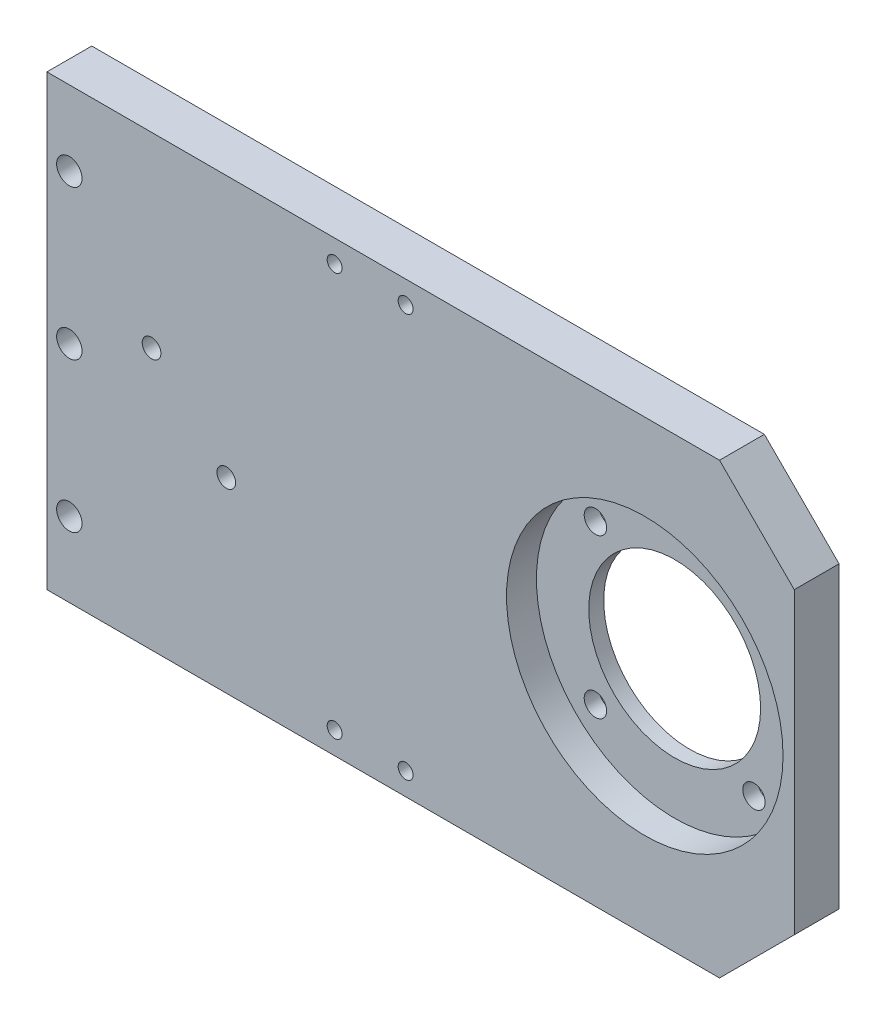
from build123d import *

# Parameters (mm, degrees)
SKETCH_1_W                = 100
SKETCH_1_H                = 60
EXTRUDE_1_DEPTH           = 6
SKETCH_2_R                = 11.5
SKETCH_2_R_2              = 1.5
CUT_EXTRUDE_1_DEPTH       = 10
SKETCH_3_R                = 18.5
CUT_EXTRUDE_2_DEPTH       = 4
HOLE_WIZARD_2_D           = 3.4
HOLE_WIZARD_2_CSINK_D     = 6.6
HOLE_WIZARD_2_CSINK_ANGLE = 90
CHAMFER_1_SIZE            = 10
HOLE_WIZARD_M3_1_D        = 2.5
HOLE_WIZARD_M3_1_DEPTH    = 7.5
HOLE_WIZARD_M3_1_TIP      = 0.751075774
SKETCH_16_R               = 1
CUT_EXTRUDE_3_DEPTH       = 6


with BuildPart() as part:
    # 草图1 → 凸台-拉伸1 (new body)
    with BuildSketch(Plane.XY):
        Rectangle(SKETCH_1_W, SKETCH_1_H)
    extrude(amount=EXTRUDE_1_DEPTH)

    # 草图2 → 切除-拉伸1 (cut)
    with BuildSketch(Plane.XY.offset(6)):
        with Locations((30, -8.8724e-05)):
            Circle(SKETCH_2_R)
        with Locations((40.606601718, 10.606512994)):
            Circle(SKETCH_2_R_2)
        with Locations((40.606601718, -10.606690441)):
            Circle(SKETCH_2_R_2)
        with Locations((19.393398282, 10.606512994)):
            Circle(SKETCH_2_R_2)
        with Locations((19.393398282, -10.606690441)):
            Circle(SKETCH_2_R_2)
    extrude(amount=-CUT_EXTRUDE_1_DEPTH, mode=Mode.SUBTRACT)

    # 草图3 → 切除-拉伸2 (cut)
    with BuildSketch(Plane.XY.offset(6)):
        with Locations((30, -8.8724e-05)):
            Circle(SKETCH_3_R)
    extrude(amount=-CUT_EXTRUDE_2_DEPTH, mode=Mode.SUBTRACT)

    # 打孔尺寸(%根据十字)槽半沉头木螺钉的类型2 (through all)
    with Locations(Plane(origin=(0, 0, 0), x_dir=(-1, 0, 0), z_dir=(0, 0, -1))):
        with Locations((47, -20), (47, 0), (47, 20)):
            CounterSinkHole(HOLE_WIZARD_2_D / 2, HOLE_WIZARD_2_CSINK_D / 2, counter_sink_angle=HOLE_WIZARD_2_CSINK_ANGLE)

    # 倒角1
    chamfer_1_edges = [part.edges().sort_by_distance(p)[0] for p in [
        (50, 30, 3),
        (50, -30, 3),
    ]]
    chamfer(chamfer_1_edges, length=CHAMFER_1_SIZE)

    # M3 螺纹孔1
    with Locations(Plane.XY.offset(6)):
        with Locations((-36, 5), (-26, -5)):
            Hole(HOLE_WIZARD_M3_1_D / 2, depth=HOLE_WIZARD_M3_1_DEPTH)
            with Locations((0, 0, -(HOLE_WIZARD_M3_1_DEPTH + HOLE_WIZARD_M3_1_TIP / 2))):  # 118° drill point
                Cone(0, HOLE_WIZARD_M3_1_D / 2, HOLE_WIZARD_M3_1_TIP, mode=Mode.SUBTRACT)

    # 草图16 → 切除-拉伸3 (cut)
    with BuildSketch(Plane.XY.offset(6)):
        with Locations((-2, 27)):
            Circle(SKETCH_16_R)
        with Locations((-11.5, 27)):
            Circle(SKETCH_16_R)
        with Locations((-11.5, -27)):
            Circle(SKETCH_16_R)
        with Locations((-2, -27)):
            Circle(SKETCH_16_R)
    extrude(amount=-CUT_EXTRUDE_3_DEPTH, mode=Mode.SUBTRACT)


solid = part.part
